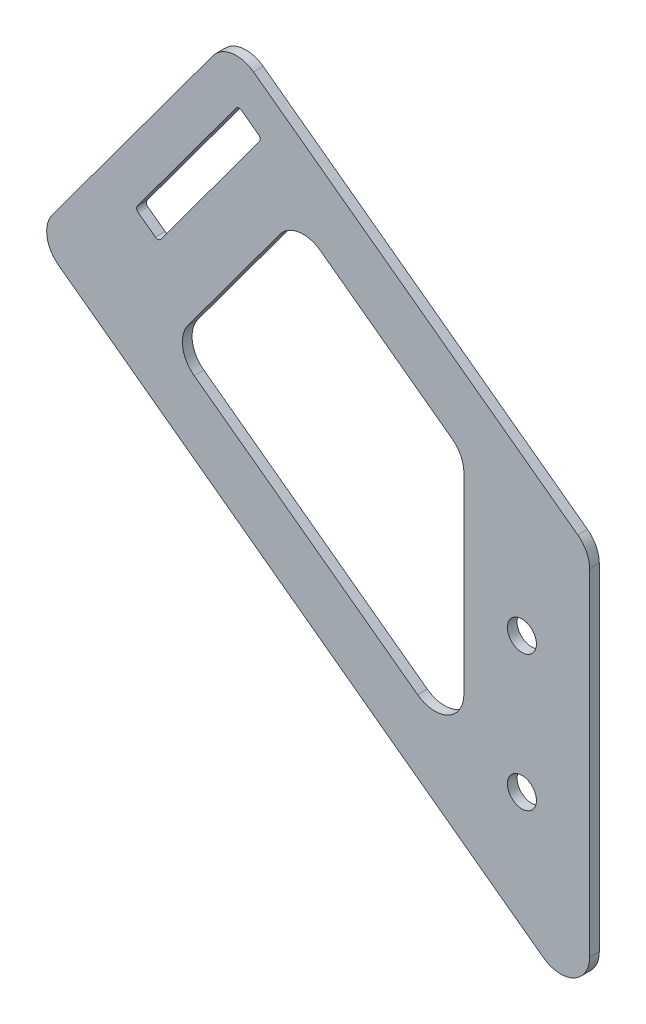
from build123d import *

# Parameters (mm, degrees)
SKETCH1_R           = 4.7625
BOSS_EXTRUDE1_DEPTH = 3.175
FILLET1_R           = 9.525


with BuildPart() as part:
    # Sketch1 → Boss-Extrude1 (new body)
    with BuildSketch(Plane.XY):
        Polygon((-195.314090033, 382.203190117), (-13.335, 248.156621006), (-13.335, 382.231468598), (-131.291653964, 469.118839915), align=None)
        with Locations((-35.56, 302.837639338)):
            Circle(SKETCH1_R, mode=Mode.SUBTRACT)
        with Locations((-35.56, 347.287639338)):
            Circle(SKETCH1_R, mode=Mode.SUBTRACT)
        with BuildLine():
            ThreePointArc((-154.070332508, 400.720749088), (-154.902423133, 400.218314877), (-155.846074695, 400.451417162))
            Line((-155.846074695, 400.451417162), (-161.470028505, 404.594045378))
            ThreePointArc((-161.470028505, 404.594045378), (-161.972462717, 405.426136003), (-161.739360431, 406.369787565))
            Line((-161.739360431, 406.369787565), (-129.351539832, 450.338880992))
            ThreePointArc((-129.351539832, 450.338880992), (-128.519449207, 450.841315204), (-127.575797645, 450.608212918))
            Line((-127.575797645, 450.608212918), (-121.951843834, 446.465584702))
            ThreePointArc((-121.951843834, 446.465584702), (-121.449409623, 445.633494077), (-121.682511908, 444.689842516))
            Line((-121.682511908, 444.689842516), (-154.070332508, 400.720749088))
        make_face(mode=Mode.SUBTRACT)
        Polygon((-150.783558745, 373.062079232), (-109.357276582, 429.301617336), (-54.61, 388.974541337), (-54.61, 302.220228189), (-96.036282162, 332.735003232), align=None, mode=Mode.SUBTRACT)
    extrude(amount=BOSS_EXTRUDE1_DEPTH)

    # Fillet1
    fillet1_edges = [part.edges().sort_by_distance(p)[0] for p in [
        (-54.61, 388.974541337, 1.5875),
        (-109.357276582, 429.301617336, 1.5875),
        (-150.783558745, 373.062079232, 1.5875),
        (-54.61, 302.220228189, 1.5875),
        (-131.291653964, 469.118839915, 1.5875),
        (-13.335, 382.231468598, 1.5875),
        (-13.335, 248.156621006, 1.5875),
        (-195.314090033, 382.203190117, 1.5875),
    ]]
    fillet(fillet1_edges, radius=FILLET1_R)


solid = part.part
